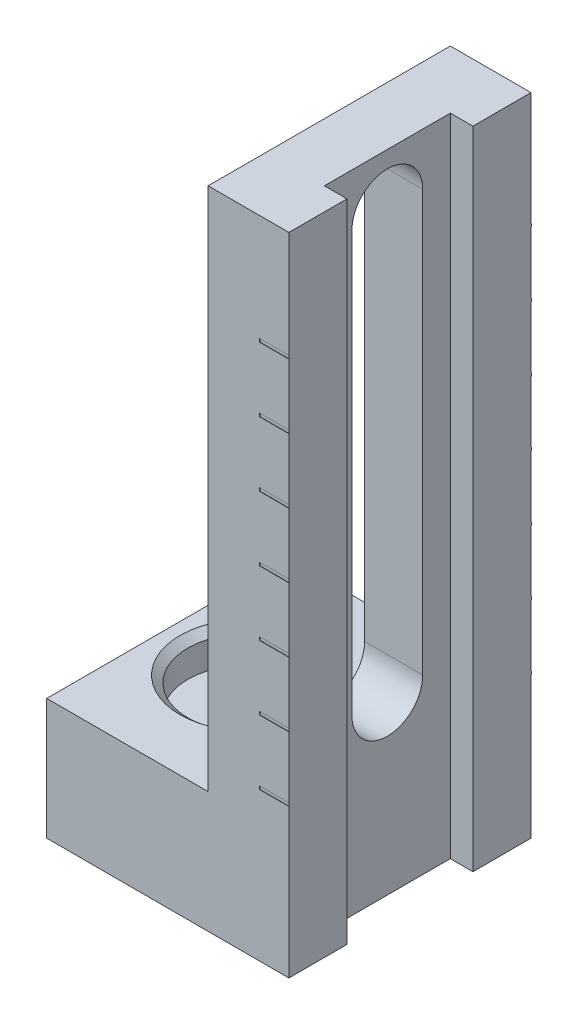
from build123d import *

# Parameters (mm, degrees)
BOSS_EXTRUDE1_DEPTH = 19.05
CUT_EXTRUDE1_REACH  = 8.35
SKETCH6_W           = 1.778
SKETCH6_H           = 9.906
CUT_EXTRUDE2_DEPTH  = 50.8
SKETCH11_W          = 2.310054712
SKETCH11_H          = 0.25
CUT_EXTRUDE3_DEPTH  = 0.02
LPATTERN1_COUNT     = 7
LPATTERN1_PITCH     = 5.08
SKETCH13_W          = 2.286
SKETCH13_H          = 0.254
BOSS_EXTRUDE2_DEPTH = 0.02
LPATTERN2_COUNT     = 7
LPATTERN2_PITCH     = 5.08


with BuildPart() as part:
    # Sketch1 → Boss-Extrude1 (new body)
    with BuildSketch(Plane.XY):
        Polygon((0, 0), (19.05, 0), (19.05, 50.8), (12.7, 50.8), (12.7, 9.525), (0, 9.525), align=None)
    extrude(amount=BOSS_EXTRUDE1_DEPTH)

    # Sketch4 → Cut-Extrude1 (cut, up to next)
    with BuildSketch(Plane.ZY.offset(-12.7), mode=Mode.PRIVATE) as cut_extrude1_sk1:
        with BuildLine():
            Line((6.742001962, 13.600990631), (6.742001962, 46.700186434))
            ThreePointArc((6.742001962, 46.700186434), (9.525, 49.483184472), (12.307998038, 46.700186434))
            Line((12.307998038, 46.700186434), (12.307998038, 13.600990631))
            ThreePointArc((12.307998038, 13.600990631), (9.525, 10.817992593), (6.742001962, 13.600990631))
        make_face()
    cut_extrude1_tool1 = extrude(cut_extrude1_sk1.sketch, amount=-CUT_EXTRUDE1_REACH, mode=Mode.PRIVATE) & part.part
    add(cut_extrude1_tool1.solids().sort_by_distance((12.7, 30.150589, 9.525))[0], mode=Mode.SUBTRACT)

    # Sketch6 → Cut-Extrude2 (cut)
    with BuildSketch(Plane(origin=(0, 50.8, 0), x_dir=(1, 0, 0), z_dir=(0, 1, 0))):
        with Locations((18.161, -9.525)):
            Rectangle(SKETCH6_W, SKETCH6_H)
    extrude(amount=-CUT_EXTRUDE2_DEPTH, mode=Mode.SUBTRACT)

    # Sketch9 → CBORE for #8 Binding Head Machine Screw1 (revolve, cut)
    with BuildSketch(Plane(origin=(6.35, 9.525, 9.525), x_dir=(0, 0, 1), z_dir=(1, 0, 0))):
        Polygon((0, 0), (0, 9.525), (2.2479, 9.525), (2.2479, 2.667), (4.7625, 2.667), (4.7625, 0.532828266), (5.3975, 0), align=None)
    revolve(axis=Axis((6.35, 15.875, 9.525), (0, -1, 0)), mode=Mode.SUBTRACT)

    # Sketch11 → Cut-Extrude3 (cut)
    with BuildSketch(Plane.XY.offset(19.05)):
        with Locations((17.894972644, 42.293)):
            Rectangle(SKETCH11_W, SKETCH11_H)
    cut_extrude3 = extrude(amount=-CUT_EXTRUDE3_DEPTH, mode=Mode.SUBTRACT)

    # LPattern1: Cut-Extrude3 ×7
    with Locations(*[(0, -i * LPATTERN1_PITCH, 0) for i in range(1, LPATTERN1_COUNT)]):
        add(cut_extrude3, mode=Mode.SUBTRACT)

    # Sketch13 → Boss-Extrude2 (add)
    with BuildSketch(Plane(origin=(0, 0, 0), x_dir=(-1, 0, 0), z_dir=(0, 0, -1))):
        with Locations((-17.907, 41.749020167)):
            Rectangle(SKETCH13_W, SKETCH13_H)
    boss_extrude2 = extrude(amount=BOSS_EXTRUDE2_DEPTH)

    # LPattern2: Boss-Extrude2 ×7
    with Locations(*[(0, -i * LPATTERN2_PITCH, 0) for i in range(1, LPATTERN2_COUNT)]):
        add(boss_extrude2)


solid = part.part
